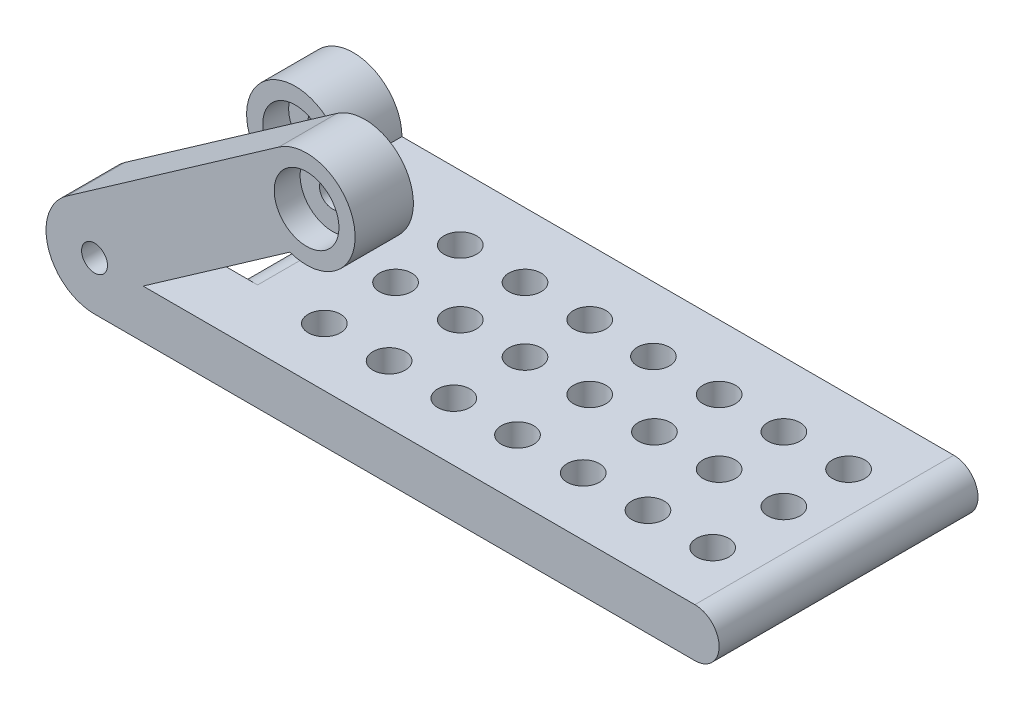
from build123d import *

# Parameters (mm, degrees)
SKETCH1_R           = 2
BOSS_EXTRUDE1_DEPTH = 40
SKETCH2_W           = 20
SKETCH2_H           = 22
CUT_EXTRUDE1_DEPTH  = 38.943057454
SKETCH3_R           = 2
CUT_EXTRUDE2_DEPTH  = 31
FILLET1_R           = 3.7
SKETCH4_R           = 2.5
CUT_EXTRUDE3_DEPTH  = 30
SKETCH5_R           = 5
CUT_EXTRUDE4_DEPTH  = 4
SKETCH11_R          = 5
CUT_EXTRUDE6_DEPTH  = 4
SKETCH12_R          = 5
CUT_EXTRUDE7_DEPTH  = 4


with BuildPart() as part:
    # Sketch1 → Boss-Extrude1 (new body)
    with BuildSketch(Plane.XY):
        with BuildLine():
            Line((28.464258499, 29.086697786), (-4.301823273, 6.143640332))
            ThreePointArc((-4.301823273, 6.143640332), (-7.152877131, -2.255293496), (0, -7.5))
            Line((0, -7.5), (92.766081772, -7.5))
            ThreePointArc((92.766081772, -7.5), (96.516081772, -3.75), (92.766081772, 0))
            Line((92.766081772, 0), (7.5, 0))
            Line((7.5, 0), (30.200930697, 15.895362798))
            ThreePointArc((30.200930697, 15.895362798), (40.201918232, 23.922003896), (28.464258499, 29.086697786))
        make_face()
        with Locations((32.766081772, 22.943057454)):
            Circle(SKETCH1_R, mode=Mode.SUBTRACT)
        Circle(SKETCH1_R, mode=Mode.SUBTRACT)
    extrude(amount=BOSS_EXTRUDE1_DEPTH)

    # Sketch2 → Cut-Extrude1 (cut, through all)
    with BuildSketch(Plane.XZ.offset(7.5)):
        with Locations((2.5, 20)):
            Rectangle(SKETCH2_W, SKETCH2_H)
    extrude(amount=-CUT_EXTRUDE1_DEPTH, mode=Mode.SUBTRACT)

    # Sketch3 → Cut-Extrude2 (cut)
    with BuildSketch(Plane(origin=(0, 0, 0), x_dir=(-1, 0, 0), z_dir=(0, 0, -1))):
        with BuildLine():
            Line((-30.200930697, 15.895362798), (-7.5, 0))
            ThreePointArc((-7.5, 0), (-3.463114599, 6.652581249), (4.301823273, 6.143640332))
            Line((4.301823273, 6.143640332), (-28.464258499, 29.086697786))
            ThreePointArc((-28.464258499, 29.086697786), (-40.201918232, 23.922003896), (-30.200930697, 15.895362798))
        make_face()
        with Locations((-32.766081772, 22.943057454)):
            Circle(SKETCH3_R, mode=Mode.SUBTRACT)
    extrude(amount=-CUT_EXTRUDE2_DEPTH, mode=Mode.SUBTRACT)

    # Fillet1
    fillet1_edges = [part.edges().sort_by_distance(p)[0] for p in [
        (12.5, 0, 20),
        (12.5, -7.5, 20),
    ]]
    fillet(fillet1_edges, radius=FILLET1_R)

    # Sketch4 → Cut-Extrude3 (cut)
    with BuildSketch(Plane(origin=(0, 0, 0), x_dir=(1, 0, 0), z_dir=(0, 1, 0))):
        with Locations((86.516081772, -10)):
            Circle(SKETCH4_R)
        with Locations((86.516081772, -20)):
            Circle(SKETCH4_R)
        with Locations((86.516081772, -31)):
            Circle(SKETCH4_R)
        with Locations((76.516081772, -31)):
            Circle(SKETCH4_R)
        with Locations((76.516081772, -20)):
            Circle(SKETCH4_R)
        with Locations((76.516081772, -10)):
            Circle(SKETCH4_R)
        with Locations((66.516081772, -10)):
            Circle(SKETCH4_R)
        with Locations((66.516081772, -20)):
            Circle(SKETCH4_R)
        with Locations((66.516081772, -31)):
            Circle(SKETCH4_R)
        with Locations((56.358040886, -31)):
            Circle(SKETCH4_R)
        with Locations((56.516081772, -20)):
            Circle(SKETCH4_R)
        with Locations((56.358040886, -10)):
            Circle(SKETCH4_R)
        with Locations((46.516081772, -10)):
            Circle(SKETCH4_R)
        with Locations((46.516081772, -20)):
            Circle(SKETCH4_R)
        with Locations((46.516081772, -31)):
            Circle(SKETCH4_R)
        with Locations((36.516081772, -31)):
            Circle(SKETCH4_R)
        with Locations((36.516081772, -20)):
            Circle(SKETCH4_R)
        with Locations((36.516081772, -10)):
            Circle(SKETCH4_R)
        with Locations((26.516081772, -10)):
            Circle(SKETCH4_R)
        with Locations((26.516081772, -20)):
            Circle(SKETCH4_R)
        with Locations((26.516081772, -31)):
            Circle(SKETCH4_R)
    extrude(amount=-CUT_EXTRUDE3_DEPTH, mode=Mode.SUBTRACT)

    # Sketch5 → Cut-Extrude4 (cut)
    with BuildSketch(Plane.XY.offset(9)):
        Circle(SKETCH5_R)
    extrude(amount=-CUT_EXTRUDE4_DEPTH, mode=Mode.SUBTRACT)

    # Sketch11 → Cut-Extrude6 (cut)
    with BuildSketch(Plane(origin=(0, 0, 31), x_dir=(-1, 0, 0), z_dir=(0, 0, -1))):
        Circle(SKETCH11_R)
    extrude(amount=-CUT_EXTRUDE6_DEPTH, mode=Mode.SUBTRACT)

    # Sketch12 → Cut-Extrude7 (cut)
    with BuildSketch(Plane.XY.offset(40)):
        with Locations((32.766081772, 22.943057454)):
            Circle(SKETCH12_R)
    extrude(amount=-CUT_EXTRUDE7_DEPTH, mode=Mode.SUBTRACT)


solid = part.part
